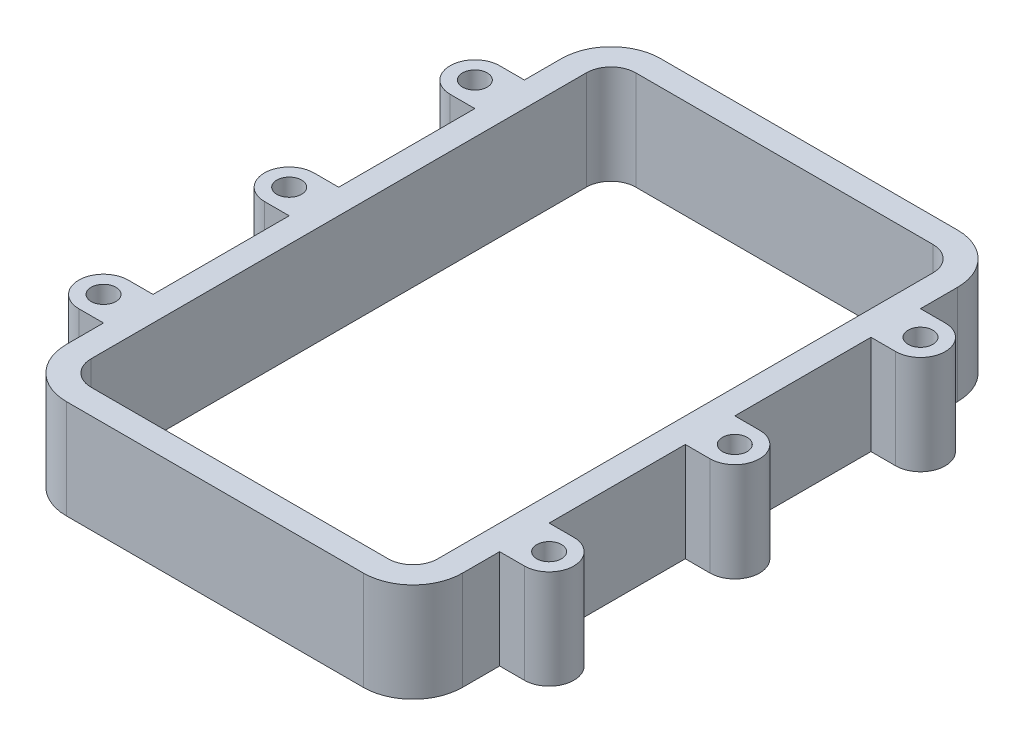
from build123d import *

# Parameters (mm, degrees)
SKETCH1_R           = 3.175
BOSS_EXTRUDE1_DEPTH = 25.4


with BuildPart() as part:
    # Sketch1 → Boss-Extrude1 (new body)
    with BuildSketch(Plane(origin=(0, 0, 0), x_dir=(1, 0, 0), z_dir=(0, 1, 0))):
        with BuildLine():
            Line((0, 76.2), (38.1, 76.2))
            ThreePointArc((38.1, 76.2), (47.080256121, 72.480256121), (50.8, 63.5))
            Line((50.8, 63.5), (50.8, 53.975))
            Line((50.8, 53.975), (57.15, 53.975))
            ThreePointArc((57.15, 53.975), (63.5, 47.625), (57.15, 41.275))
            Line((57.15, 41.275), (50.8, 41.275))
            Line((50.8, 41.275), (50.8, 6.35))
            Line((50.8, 6.35), (57.15, 6.35))
            ThreePointArc((57.15, 6.35), (63.5, 0), (57.15, -6.35))
            Line((57.15, -6.35), (50.8, -6.35))
            Line((50.8, -6.35), (50.8, -41.275))
            Line((50.8, -41.275), (57.15, -41.275))
            ThreePointArc((57.15, -41.275), (63.5, -47.625), (57.15, -53.975))
            Line((57.15, -53.975), (50.8, -53.975))
            Line((50.8, -53.975), (50.8, -63.5))
            ThreePointArc((50.8, -63.5), (47.080256121, -72.480256121), (38.1, -76.2))
            Line((38.1, -76.2), (-4.318973468, -76.2))
            Line((-4.318973468, -76.2), (-38.1, -76.2))
            ThreePointArc((-38.1, -76.2), (-47.080256121, -72.480256121), (-50.8, -63.5))
            Line((-50.8, -63.5), (-50.8, -53.975))
            Line((-50.8, -53.975), (-57.15, -53.975))
            ThreePointArc((-57.15, -53.975), (-63.5, -47.625), (-57.15, -41.275))
            Line((-57.15, -41.275), (-50.8, -41.275))
            Line((-50.8, -41.275), (-50.8, -6.35))
            Line((-50.8, -6.35), (-57.15, -6.35))
            ThreePointArc((-57.15, -6.35), (-63.5, 0), (-57.15, 6.35))
            Line((-57.15, 6.35), (-50.8, 6.35))
            Line((-50.8, 6.35), (-50.8, 41.275))
            Line((-50.8, 41.275), (-57.15, 41.275))
            ThreePointArc((-57.15, 41.275), (-63.5, 47.625), (-57.15, 53.975))
            Line((-57.15, 53.975), (-50.8, 53.975))
            Line((-50.8, 53.975), (-50.8, 63.5))
            ThreePointArc((-50.8, 63.5), (-47.080256121, 72.480256121), (-38.1, 76.2))
            Line((-38.1, 76.2), (0, 76.2))
        make_face()
        with Locations((57.15, 47.625)):
            Circle(SKETCH1_R, mode=Mode.SUBTRACT)
        with Locations((57.15, 0)):
            Circle(SKETCH1_R, mode=Mode.SUBTRACT)
        with Locations((57.15, -47.625)):
            Circle(SKETCH1_R, mode=Mode.SUBTRACT)
        with Locations((-57.15, -47.625)):
            Circle(SKETCH1_R, mode=Mode.SUBTRACT)
        with Locations((-57.15, 47.625)):
            Circle(SKETCH1_R, mode=Mode.SUBTRACT)
        with Locations((-57.15, 0)):
            Circle(SKETCH1_R, mode=Mode.SUBTRACT)
        with BuildLine():
            Line((0, 69.85), (38.1, 69.85))
            ThreePointArc((38.1, 69.85), (42.590128061, 67.990128061), (44.45, 63.5))
            Line((44.45, 63.5), (44.45, -63.5))
            ThreePointArc((44.45, -63.5), (42.590128061, -67.990128061), (38.1, -69.85))
            Line((38.1, -69.85), (-4.318973468, -69.85))
            Line((-4.318973468, -69.85), (-38.1, -69.85))
            ThreePointArc((-38.1, -69.85), (-42.590128061, -67.990128061), (-44.45, -63.5))
            Line((-44.45, -63.5), (-44.45, 63.5))
            ThreePointArc((-44.45, 63.5), (-42.590128061, 67.990128061), (-38.1, 69.85))
            Line((-38.1, 69.85), (0, 69.85))
        make_face(mode=Mode.SUBTRACT)
    extrude(amount=BOSS_EXTRUDE1_DEPTH)


solid = part.part
